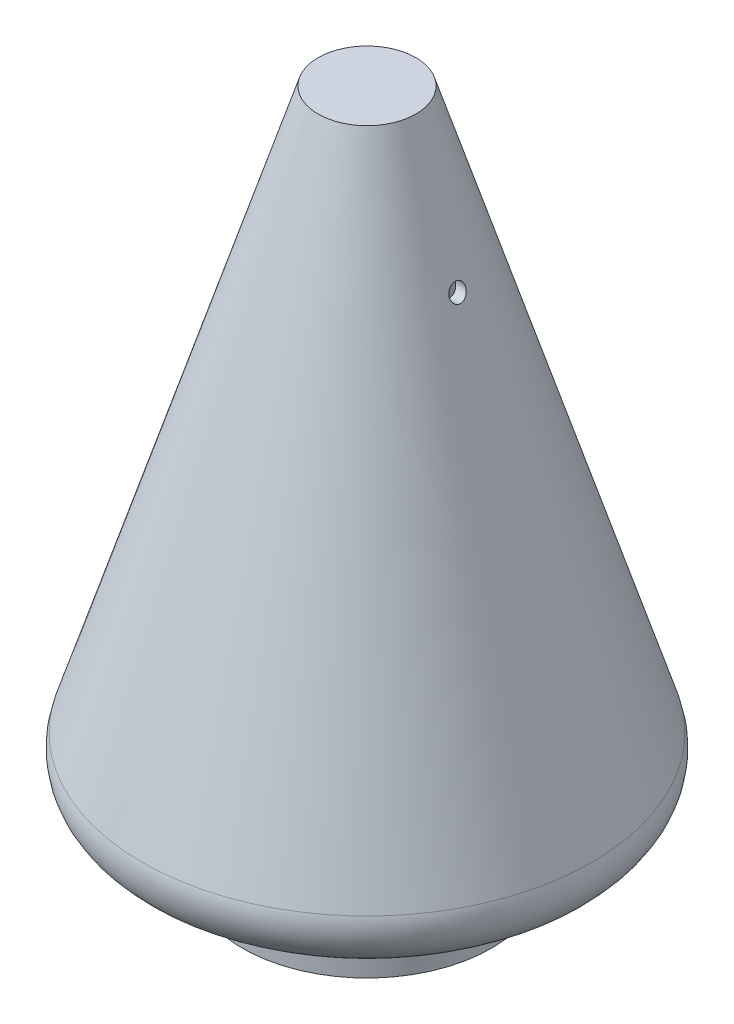
from build123d import *

# Parameters (mm, degrees)
CORTE_EXTRUS_O1_REACH = 208
ESBO_O2_R             = 2.5
ESBO_O4_R             = 2.5
CORTE_EXTRUS_O2_DEPTH = 50
ESBO_O5_R             = 2.5
CORTE_EXTRUS_O3_DEPTH = 110


with BuildPart() as part:
    # Esboço1 → Revolução1 (revolve)
    with BuildSketch(Plane.XY, mode=Mode.PRIVATE) as revolu_o1_sk:
        with BuildLine():
            Line((0, 0), (10, 0))
            Line((10, 0), (34.5, 10.652173913))
            Line((34.5, 10.652173913), (34.5, 86.956521739))
            Line((34.5, 86.956521739), (37.5, 86.956521739))
            Line((37.5, 86.956521739), (37.5, 11.956521739))
            Line((37.5, 11.956521739), (59.250106277, 21.413089686))
            ThreePointArc((59.250106277, 21.413089686), (64.360493758, 26.432550668), (64.802782332, 33.582056216))
            Line((64.802782332, 33.582056216), (12.5, 200))
            Line((12.5, 200), (0, 200))
            Line((0, 200), (0, 203))
            Line((0, 203), (14.701817656, 203))
            Line((14.701817656, 203), (67.664763483, 34.481536006))
            ThreePointArc((67.664763483, 34.481536006), (67.089788336, 25.187178794), (60.446284612, 18.661879517))
            Line((60.446284612, 18.661879517), (37.5, 8.685234034))
            Line((37.5, 8.685234034), (37.5, -3))
            Line((37.5, -3), (10.623961722, -3))
            Line((10.623961722, -3), (0, -3))
            Line((0, -3), (0, 0))
        make_face()
    revolve(revolu_o1_sk.sketch.rotate(Axis((0, 0, 0), (0, 1, 0)), 90), axis=Axis((0, 0, 0), (0, 1, 0)))  # turned: the seam where the file's is

    # Esboço2 → Corte-extrusão1 (cut, up to next)
    with BuildSketch(Plane.XZ.offset(3), mode=Mode.PRIVATE) as corte_extrus_o1_sk1:
        with Locations(Location((0, 0, 0), (0, 0, 270))):  # turned: the seam where the file's is
            Circle(ESBO_O2_R)
    corte_extrus_o1_tool1 = extrude(corte_extrus_o1_sk1.sketch, amount=-CORTE_EXTRUS_O1_REACH, mode=Mode.PRIVATE) & part.part
    add(corte_extrus_o1_tool1.solids().sort_by_distance((0, -3, 0))[0], mode=Mode.SUBTRACT)

    # Esboço4 → Corte-extrusão2 (cut)
    with BuildSketch(Plane(origin=(0, 0, 0), x_dir=(0, 0, -1), z_dir=(1, 0, 0))):
        with Locations(Location((0, 162.819249831, 0), (0, 0, 306.470564915))):  # turned: the seam where the file's is
            Circle(ESBO_O4_R)
    extrude(amount=CORTE_EXTRUS_O2_DEPTH, mode=Mode.SUBTRACT)

    # Esboço5 → Corte-extrusão3 (cut)
    with BuildSketch(Plane.XY):
        with Locations(Location((0, 57.186880689, 0), (0, 0, 90))):  # turned: the seam where the file's is
            Circle(ESBO_O5_R)
    extrude(amount=-CORTE_EXTRUS_O3_DEPTH, mode=Mode.SUBTRACT)


solid = part.part
